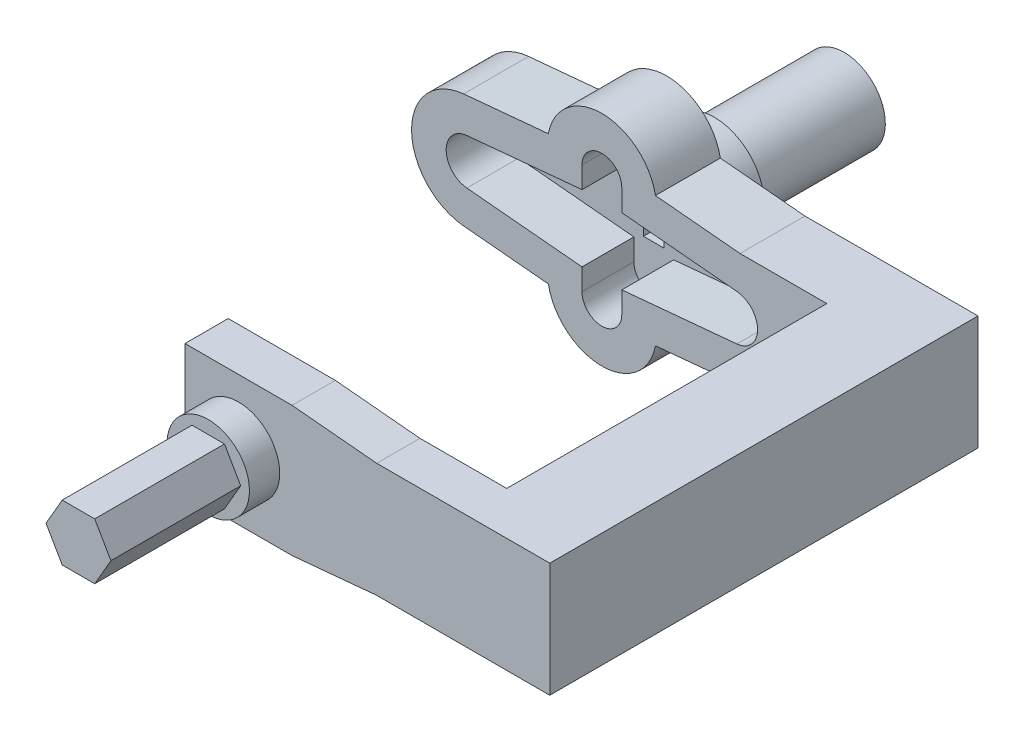
from build123d import *

# Parameters (mm, degrees)
BOSS_EXTRUDE1_DEPTH = 6
BOSS_EXTRUDE2_DEPTH = 7
SKETCH4_R           = 4.7625
BOSS_EXTRUDE3_DEPTH = 15
CUT_EXTRUDE1_REACH  = 30
SKETCH5_W           = 2.4
SKETCH5_H           = 6.5
SKETCH8_W           = 9.974420143
SKETCH8_H           = 13.222039712
BOSS_EXTRUDE4_DEPTH = 37
BOSS_EXTRUDE5_DEPTH = 5
SKETCH12_R          = 4.7625
BOSS_EXTRUDE6_DEPTH = 3.5
BOSS_EXTRUDE7_DEPTH = 15
SKETCH14_W          = 83.87720003
SKETCH14_H          = 67.677452278
SKETCH14_R          = 5.7625
CUT_EXTRUDE2_DEPTH  = 5.5


with BuildPart() as part:
    # Sketch2 → Boss-Extrude1 (new body)
    with BuildSketch(Plane.XY):
        with BuildLine():
            Line((15.974420143, 6.611019856), (35.974420143, 6.611019856))
            Line((35.974420143, 6.611019856), (35.974420143, -6.611019856))
            Line((35.974420143, -6.611019856), (15.974420143, -6.611019856))
            Line((15.974420143, -6.611019856), (6.190493175, -7.51952736))
            ThreePointArc((6.190493175, -7.51952736), (0, -12.65), (-6.190493175, -7.51952736))
            Line((-6.190493175, -7.51952736), (-15.974420143, -6.611019856))
            ThreePointArc((-15.974420143, -6.611019856), (-22, 0), (-15.974420143, 6.611019856))
            Line((-15.974420143, 6.611019856), (-6.190493175, 7.51952736))
            ThreePointArc((-6.190493175, 7.51952736), (0, 12.65), (6.190493175, 7.51952736))
            Line((6.190493175, 7.51952736), (15.974420143, 6.611019856))
        make_face()
        with BuildLine():
            Line((15.604582602, 2.62815403), (2.3, 3.863579557))
            Line((2.3, 3.863579557), (2.3, 6.35))
            ThreePointArc((2.3, 6.35), (0, 8.65), (-2.3, 6.35))
            Line((-2.3, 6.35), (-2.3, 3.863579557))
            Line((-2.3, 3.863579557), (-15.604582602, 2.62815403))
            ThreePointArc((-15.604582602, 2.62815403), (-18, 0), (-15.604582602, -2.62815403))
            Line((-15.604582602, -2.62815403), (-2.3, -3.863579557))
            Line((-2.3, -3.863579557), (-2.3, -6.35))
            ThreePointArc((-2.3, -6.35), (0, -8.65), (2.3, -6.35))
            Line((2.3, -6.35), (2.3, -3.863579557))
            Line((2.3, -3.863579557), (15.604582602, -2.62815403))
            ThreePointArc((15.604582602, -2.62815403), (18, 0), (15.604582602, 2.62815403))
        make_face(mode=Mode.SUBTRACT)
    extrude(amount=BOSS_EXTRUDE1_DEPTH)

    # Sketch3 → Boss-Extrude2 (add)
    with BuildSketch(Plane(origin=(0, 0, 0), x_dir=(-1, 0, 0), z_dir=(0, 0, -1))):
        with BuildLine():
            Line((-15.974420143, -6.611019856), (-6.190493175, -7.51952736))
            ThreePointArc((-6.190493175, -7.51952736), (0, -12.65), (6.190493175, -7.51952736))
            Line((6.190493175, -7.51952736), (15.974420143, -6.611019856))
            ThreePointArc((15.974420143, -6.611019856), (22, 0), (15.974420143, 6.611019856))
            Line((15.974420143, 6.611019856), (6.190493175, 7.51952736))
            ThreePointArc((6.190493175, 7.51952736), (0, 12.65), (-6.190493175, 7.51952736))
            Line((-6.190493175, 7.51952736), (-15.974420143, 6.611019856))
            Line((-15.974420143, 6.611019856), (-35.974420143, 6.611019856))
            Line((-35.974420143, 6.611019856), (-35.974420143, -6.611019856))
            Line((-35.974420143, -6.611019856), (-15.974420143, -6.611019856))
        make_face()
    extrude(amount=BOSS_EXTRUDE2_DEPTH)

    # Sketch4 → Boss-Extrude3 (add)
    with BuildSketch(Plane(origin=(0, 0, -7), x_dir=(-1, 0, 0), z_dir=(0, 0, -1))):
        with Locations(Location((0, 0, 0), (0, 0, 90))):  # turned: the seam where the file's is
            Circle(SKETCH4_R)
    extrude(amount=BOSS_EXTRUDE3_DEPTH)

    # Sketch5 → Cut-Extrude1 (cut, up to next)
    with BuildSketch(Plane(origin=(0, 0, -22), x_dir=(-1, 0, 0), z_dir=(0, 0, -1)), mode=Mode.PRIVATE) as cut_extrude1_sk1:
        Rectangle(SKETCH5_W, SKETCH5_H)
    cut_extrude1_tool1 = extrude(cut_extrude1_sk1.sketch, amount=-CUT_EXTRUDE1_REACH, mode=Mode.PRIVATE) & part.part
    add(cut_extrude1_tool1.solids().sort_by_distance((0, 0, -22))[0], mode=Mode.SUBTRACT)

    # Sketch8 → Boss-Extrude4 (add)
    with BuildSketch(Plane.XY.offset(6)):
        with Locations((30.987210072, 0)):
            Rectangle(SKETCH8_W, SKETCH8_H)
    extrude(amount=BOSS_EXTRUDE4_DEPTH)

    # Sketch10 → Boss-Extrude5 (add)
    with BuildSketch(Plane.XY.offset(43)):
        Polygon((35.974420143, 6.611019856), (15.974420143, 6.611019856), (6.190493175, 7.51952736), (-6.190493175, 7.51952736), (-6.190493175, -7.51952736), (6.190493175, -7.51952736), (15.974420143, -6.611019856), (35.974420143, -6.611019856), align=None)
    extrude(amount=BOSS_EXTRUDE5_DEPTH)

    # Sketch12 → Boss-Extrude6 (add)
    with BuildSketch(Plane.XY.offset(48)):
        with Locations(Location((0, 0, 0), (0, 0, 90))):  # turned: the seam where the file's is
            Circle(SKETCH12_R)
    extrude(amount=BOSS_EXTRUDE6_DEPTH)

    # Sketch13 → Boss-Extrude7 (add)
    with BuildSketch(Plane.XY.offset(51.5)):
        Polygon((3.75277675, 0), (1.876388375, 3.25), (-1.876388375, 3.25), (-3.75277675, 0), (-1.876388375, -3.25), (1.876388375, -3.25), align=None)
    extrude(amount=BOSS_EXTRUDE7_DEPTH)

    # Sketch14 → Cut-Extrude2 (cut)
    with BuildSketch(Plane(origin=(0, 0, -7), x_dir=(-1, 0, 0), z_dir=(0, 0, -1))):
        with Locations((-8.599932489, 1.250992594)):
            Rectangle(SKETCH14_W, SKETCH14_H)
        with BuildLine():
            Line((-35.974420143, -6.611019856), (-15.974420143, -6.611019856))
            Line((-15.974420143, -6.611019856), (-6.190493175, -7.51952736))
            ThreePointArc((-6.190493175, -7.51952736), (0, -12.65), (6.190493175, -7.51952736))
            Line((6.190493175, -7.51952736), (15.974420143, -6.611019856))
            ThreePointArc((15.974420143, -6.611019856), (22, 0), (15.974420143, 6.611019856))
            Line((15.974420143, 6.611019856), (6.190493175, 7.51952736))
            ThreePointArc((6.190493175, 7.51952736), (0, 12.65), (-6.190493175, 7.51952736))
            Line((-6.190493175, 7.51952736), (-15.974420143, 6.611019856))
            Line((-15.974420143, 6.611019856), (-35.974420143, 6.611019856))
            Line((-35.974420143, 6.611019856), (-35.974420143, -6.611019856))
        make_face(mode=Mode.SUBTRACT)
        with BuildLine():
            Line((-35.974420143, 6.611019856), (-35.974420143, -6.611019856))
            Line((-35.974420143, -6.611019856), (-15.974420143, -6.611019856))
            Line((-15.974420143, -6.611019856), (-6.190493175, -7.51952736))
            ThreePointArc((-6.190493175, -7.51952736), (0, -12.65), (6.190493175, -7.51952736))
            Line((6.190493175, -7.51952736), (15.974420143, -6.611019856))
            ThreePointArc((15.974420143, -6.611019856), (22, 0), (15.974420143, 6.611019856))
            Line((15.974420143, 6.611019856), (6.190493175, 7.51952736))
            ThreePointArc((6.190493175, 7.51952736), (0, 12.65), (-6.190493175, 7.51952736))
            Line((-6.190493175, 7.51952736), (-15.974420143, 6.611019856))
            Line((-15.974420143, 6.611019856), (-35.974420143, 6.611019856))
        make_face()
        with Locations(Location((0, 0, 0), (0, 0, 90))):  # turned: the seam where the file's is
            Circle(SKETCH14_R, mode=Mode.SUBTRACT)
    extrude(amount=-CUT_EXTRUDE2_DEPTH, mode=Mode.SUBTRACT)


solid = part.part
